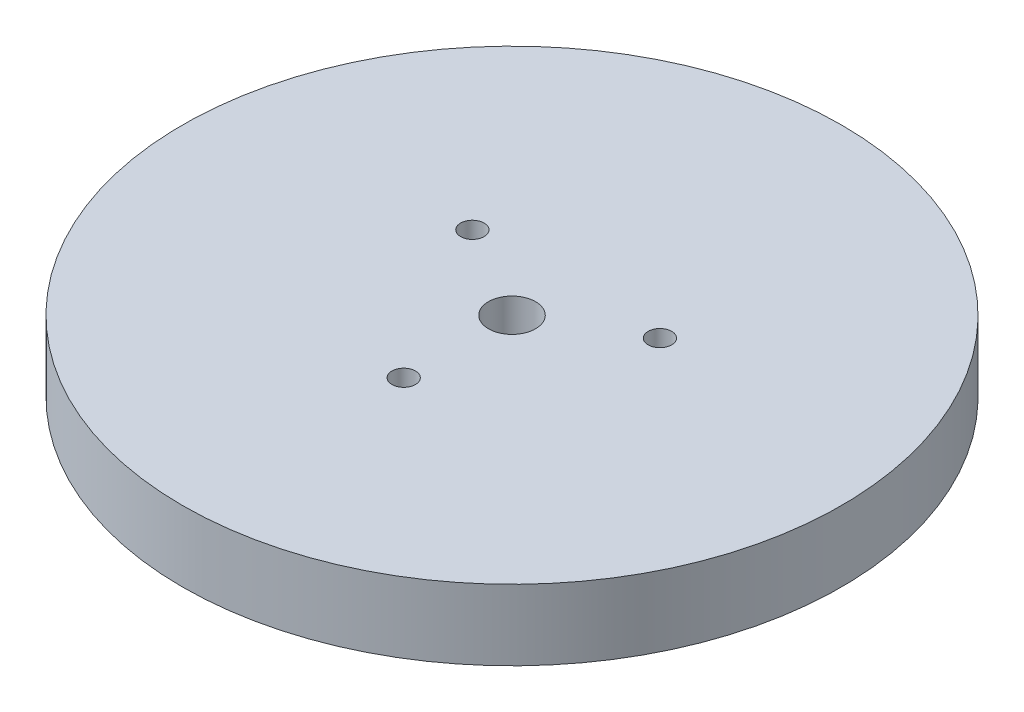
from build123d import *

# Parameters (mm, degrees)
SKETCH1_R           = 70
BOSS_EXTRUDE1_DEPTH = 15
SKETCH2_R           = 5
CUT_EXTRUDE1_DEPTH  = 15
SKETCH3_R           = 2.5
CUT_EXTRUDE2_DEPTH  = 16


with BuildPart() as part:
    # Sketch1 → Boss-Extrude1 (new body)
    with BuildSketch(Plane(origin=(0, 0, 0), x_dir=(1, 0, 0), z_dir=(0, 1, 0))):
        Circle(SKETCH1_R)
    extrude(amount=BOSS_EXTRUDE1_DEPTH)

    # Sketch2 → Cut-Extrude1 (cut)
    with BuildSketch(Plane(origin=(0, 15, 0), x_dir=(1, 0, 0), z_dir=(0, 1, 0))):
        Circle(SKETCH2_R)
    extrude(amount=-CUT_EXTRUDE1_DEPTH, mode=Mode.SUBTRACT)

    # Sketch3 → Cut-Extrude2 (cut, through all)
    with BuildSketch(Plane.XZ):
        with Locations((0, 23)):
            Circle(SKETCH3_R)
        with Locations((19.918584287, -11.5)):
            Circle(SKETCH3_R)
        with Locations((-19.918584287, -11.5)):
            Circle(SKETCH3_R)
    extrude(amount=-CUT_EXTRUDE2_DEPTH, mode=Mode.SUBTRACT)


solid = part.part
